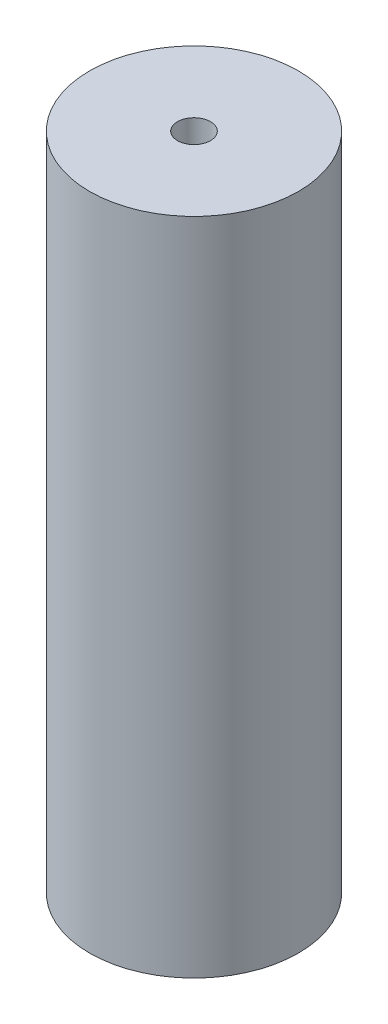
from build123d import *

# Parameters (mm, degrees)
SKETCH2_R           = 9.5
BOSS_EXTRUDE1_DEPTH = 30
SKETCH3_R           = 1.5
CUT_EXTRUDE1_DEPTH  = 61


with BuildPart() as part:
    # Sketch2 → Boss-Extrude1 (new body, symmetric)
    with BuildSketch(Plane(origin=(0, 0, 0), x_dir=(1, 0, 0), z_dir=(0, 1, 0))):
        Circle(SKETCH2_R)
    extrude(amount=BOSS_EXTRUDE1_DEPTH, both=True)

    # Sketch3 → Cut-Extrude1 (cut, through all)
    with BuildSketch(Plane(origin=(0, 30, 0), x_dir=(1, 0, 0), z_dir=(0, 1, 0))):
        Circle(SKETCH3_R)
    extrude(amount=-CUT_EXTRUDE1_DEPTH, mode=Mode.SUBTRACT)


solid = part.part
